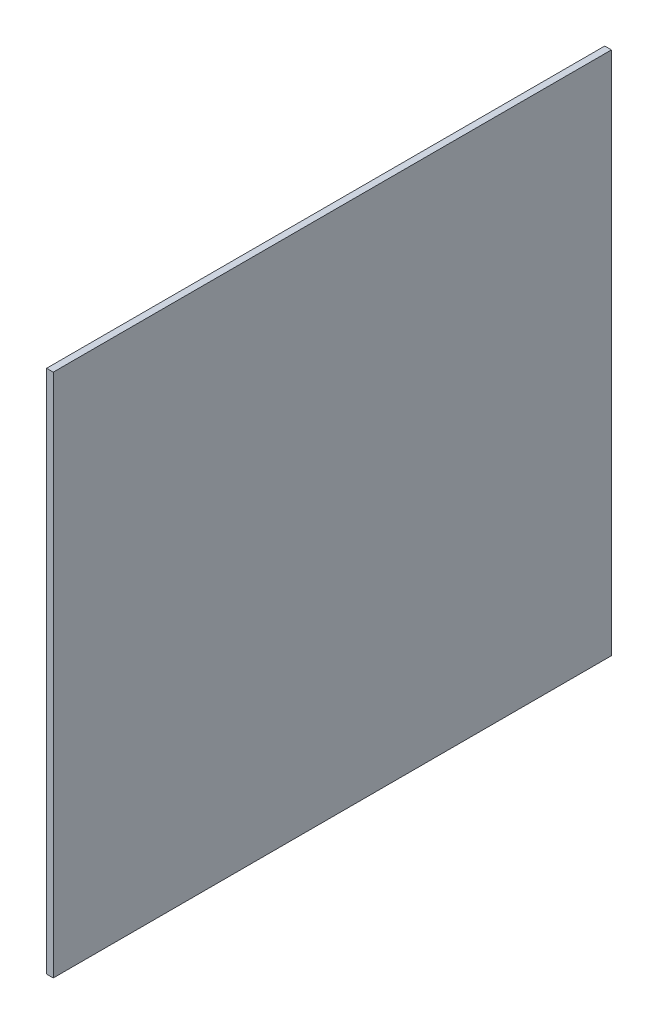
from build123d import *

# Parameters (mm, degrees)
SKETCH1_W           = 5000
SKETCH1_H           = 4700
BOSS_EXTRUDE1_DEPTH = 60


with BuildPart() as part:
    # Sketch1 → Boss-Extrude1 (new body)
    with BuildSketch(Plane(origin=(0, 0, 0), x_dir=(0, 0, -1), z_dir=(1, 0, 0))):
        Rectangle(SKETCH1_W, SKETCH1_H)
    extrude(amount=BOSS_EXTRUDE1_DEPTH)


solid = part.part
